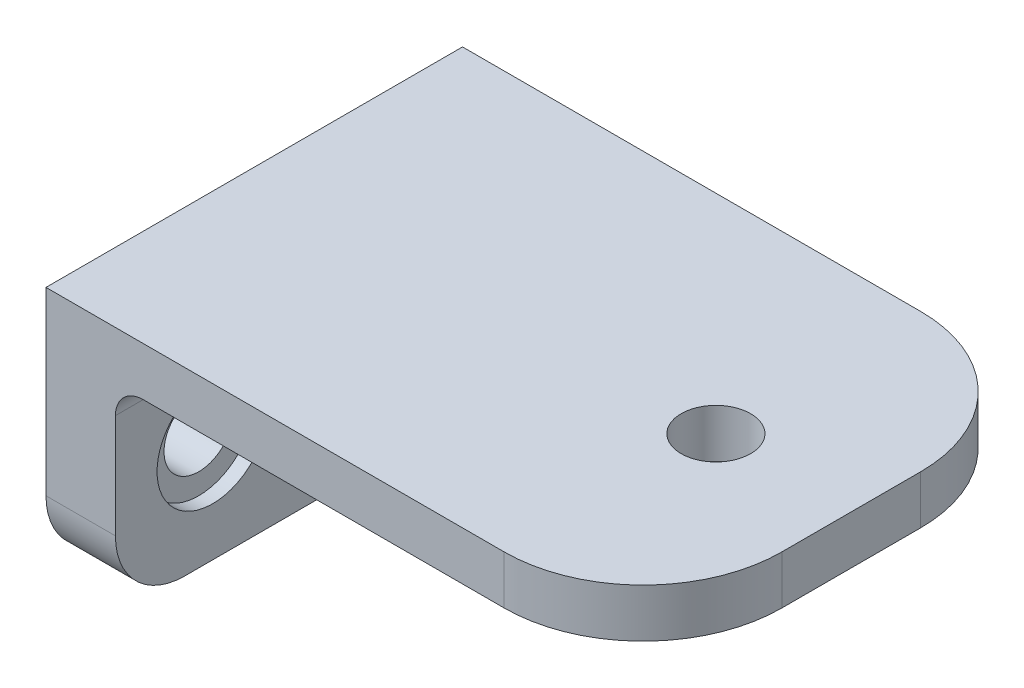
from build123d import *

# Parameters (mm, degrees)
SKETCH1_W           = 38
SKETCH1_H           = 30
BOSS_EXTRUDE1_DEPTH = 3.5
SKETCH2_W           = 30
SKETCH2_H           = 18
BOSS_EXTRUDE2_DEPTH = 5
SKETCH3_R           = 4
CUT_EXTRUDE1_DEPTH  = 1
SKETCH4_R           = 2.5
CUT_EXTRUDE2_DEPTH  = 5
SKETCH5_R           = 2.5
CUT_EXTRUDE3_DEPTH  = 5
FILLET1_R           = 10
FILLET2_R           = 2
FILLET3_R           = 5


with BuildPart() as part:
    # Sketch1 → Boss-Extrude1 (new body)
    with BuildSketch(Plane(origin=(0, 0, 0), x_dir=(1, 0, 0), z_dir=(0, 1, 0))):
        Rectangle(SKETCH1_W, SKETCH1_H)
    extrude(amount=BOSS_EXTRUDE1_DEPTH)

    # Sketch2 → Boss-Extrude2 (add)
    with BuildSketch(Plane.ZY.offset(19)):
        with Locations((0, -5.5)):
            Rectangle(SKETCH2_W, SKETCH2_H)
    extrude(amount=BOSS_EXTRUDE2_DEPTH)

    # Sketch3 → Cut-Extrude1 (cut)
    with BuildSketch(Plane(origin=(-19, 0, 0), x_dir=(0, 0, -1), z_dir=(1, 0, 0))):
        with Locations((-8, -7)):
            Circle(SKETCH3_R)
        with Locations((8, -7)):
            Circle(SKETCH3_R)
    extrude(amount=-CUT_EXTRUDE1_DEPTH, mode=Mode.SUBTRACT)

    # Sketch4 → Cut-Extrude2 (cut)
    with BuildSketch(Plane(origin=(-20, 0, 0), x_dir=(0, 0, -1), z_dir=(1, 0, 0))):
        with Locations((-8, -7)):
            Circle(SKETCH4_R)
        with Locations((8, -7)):
            Circle(SKETCH4_R)
    extrude(amount=-CUT_EXTRUDE2_DEPTH, mode=Mode.SUBTRACT)

    # Sketch5 → Cut-Extrude3 (cut)
    with BuildSketch(Plane(origin=(0, 3.5, 0), x_dir=(1, 0, 0), z_dir=(0, 1, 0))):
        with Locations((9.25, 0)):
            Circle(SKETCH5_R)
    extrude(amount=-CUT_EXTRUDE3_DEPTH, mode=Mode.SUBTRACT)

    # Fillet1
    fillet1_edges = [part.edges().sort_by_distance(p)[0] for p in [
        (19, 1.75, -15),
        (19, 1.75, 15),
    ]]
    fillet(fillet1_edges, radius=FILLET1_R)

    # Fillet2
    fillet2_edges = [part.edges().sort_by_distance(p)[0] for p in [
        (-19, 0, 0),
    ]]
    fillet(fillet2_edges, radius=FILLET2_R)

    # Fillet3
    fillet3_edges = [part.edges().sort_by_distance(p)[0] for p in [
        (-21.5, -14.5, -15),
        (-21.5, -14.5, 15),
    ]]
    fillet(fillet3_edges, radius=FILLET3_R)


solid = part.part
